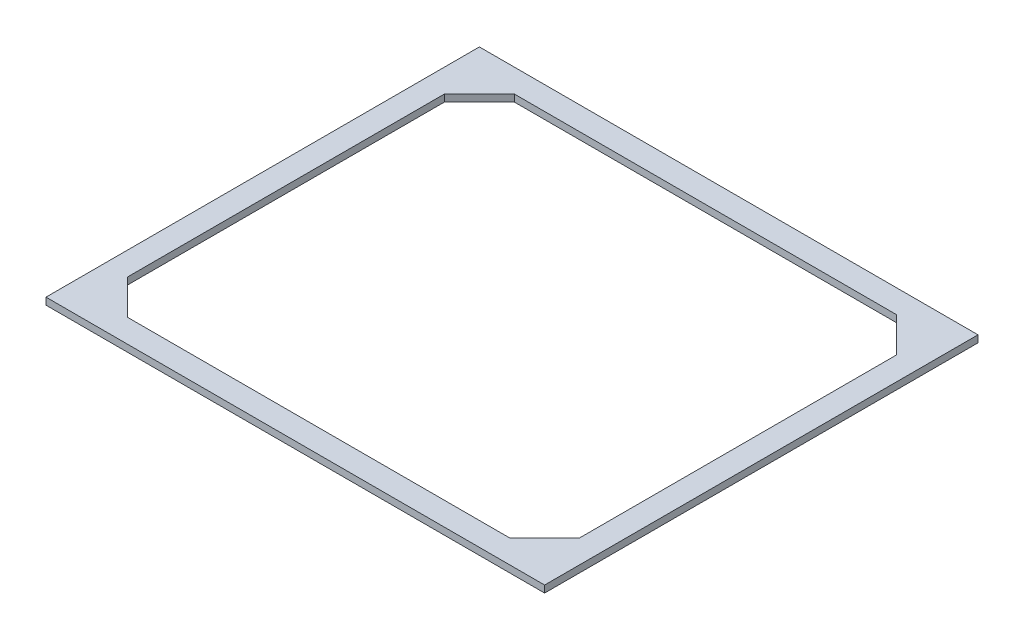
from build123d import *

# Parameters (mm, degrees)
SKETCH1_W           = 214
SKETCH1_H           = 186
BOSS_EXTRUDE1_DEPTH = 3


with BuildPart() as part:
    # Sketch1 → Boss-Extrude1 (new body)
    with BuildSketch(Plane(origin=(0, 0, 0), x_dir=(1, 0, 0), z_dir=(0, 1, 0))):
        Rectangle(SKETCH1_W, SKETCH1_H)
        Polygon((-82, 83), (82, 83), (97, 68), (97, -68), (82, -83), (-82, -83), (-97, -68), (-97, 68), align=None, mode=Mode.SUBTRACT)
    extrude(amount=BOSS_EXTRUDE1_DEPTH)


solid = part.part
